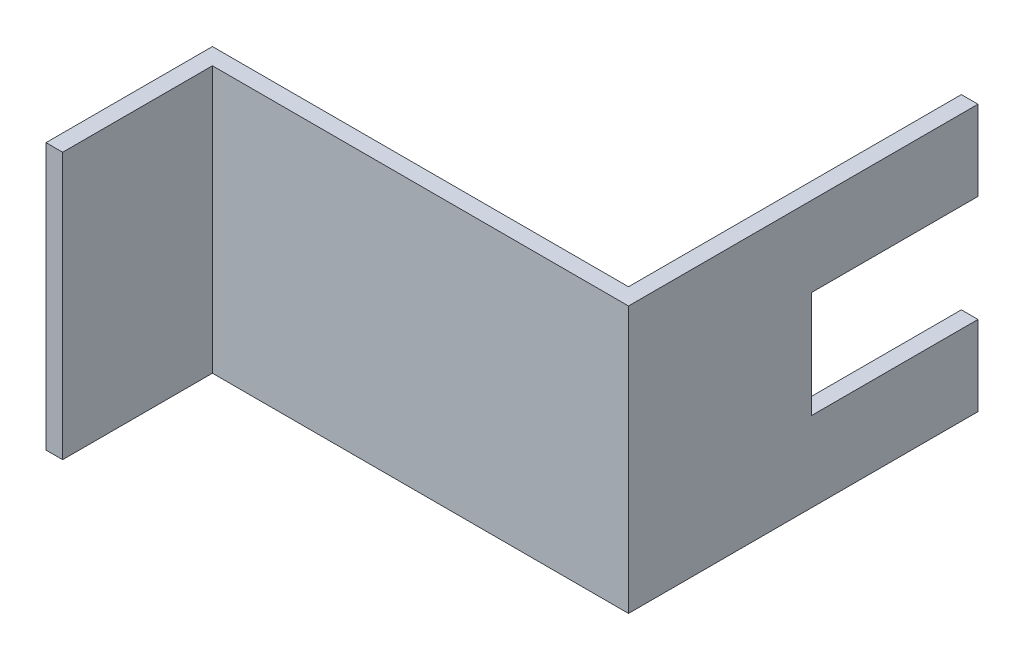
from build123d import *

# Parameters (mm, degrees)
SKETCH1_W           = 38.1
SKETCH1_H           = 1.5875
BOSS_EXTRUDE1_DEPTH = 25.4
SKETCH2_W           = 15.875
SKETCH2_H           = 10.16
CUT_EXTRUDE1_DEPTH  = 25.4


with BuildPart() as part:
    # Sketch1 → Boss-Extrude1 (new body)
    with BuildSketch(Plane(origin=(0, 0, 0), x_dir=(1, 0, 0), z_dir=(0, 1, 0))):
        Polygon((26.476413323, 23.684114825), (24.888913323, 23.684114825), (24.888913323, -8.065885175), (24.888913323, -9.653385175), (26.476413323, -9.653385175), align=None)
        with Locations((5.838913323, -8.859635175)):
            Rectangle(SKETCH1_W, SKETCH1_H)
        Polygon((-13.211086677, -9.653385175), (-13.211086677, -8.065885175), (-14.798586677, -8.065885175), (-14.798586677, -23.940885175), (-13.211086677, -23.940885175), align=None)
    extrude(amount=BOSS_EXTRUDE1_DEPTH)

    # Sketch2 → Cut-Extrude1 (cut)
    with BuildSketch(Plane(origin=(26.476413323, 0, 0), x_dir=(0, 0, -1), z_dir=(1, 0, 0))):
        with Locations((15.746614825, 12.7)):
            Rectangle(SKETCH2_W, SKETCH2_H)
    extrude(amount=-CUT_EXTRUDE1_DEPTH, mode=Mode.SUBTRACT)


solid = part.part
